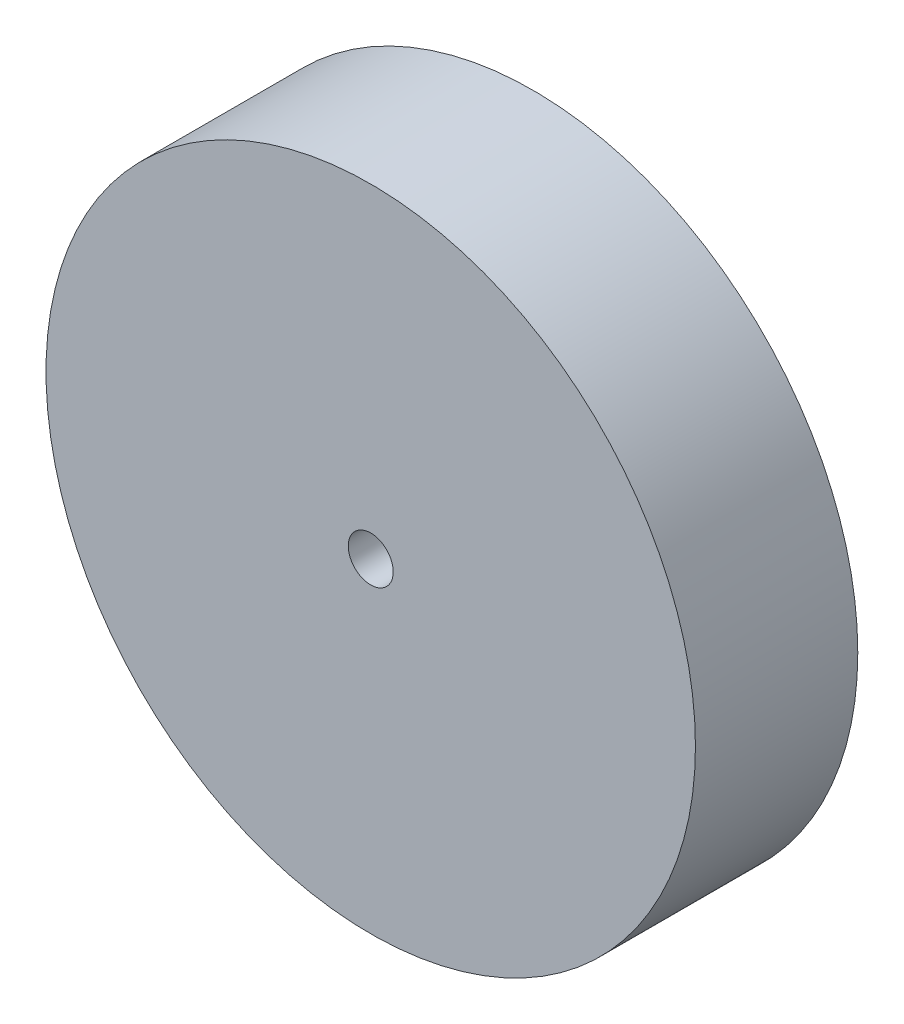
from build123d import *

# Parameters (mm, degrees)
SKETCH1_R           = 10
BOSS_EXTRUDE1_DEPTH = 5
SKETCH2_R           = 0.69285
CUT_EXTRUDE1_DEPTH  = 10


with BuildPart() as part:
    # Sketch1 → Boss-Extrude1 (new body)
    with BuildSketch(Plane.XY):
        Circle(SKETCH1_R)
    extrude(amount=BOSS_EXTRUDE1_DEPTH)

    # Sketch2 → Cut-Extrude1 (cut)
    with BuildSketch(Plane.XY.offset(5)):
        Circle(SKETCH2_R)
    extrude(amount=-CUT_EXTRUDE1_DEPTH, mode=Mode.SUBTRACT)


solid = part.part
